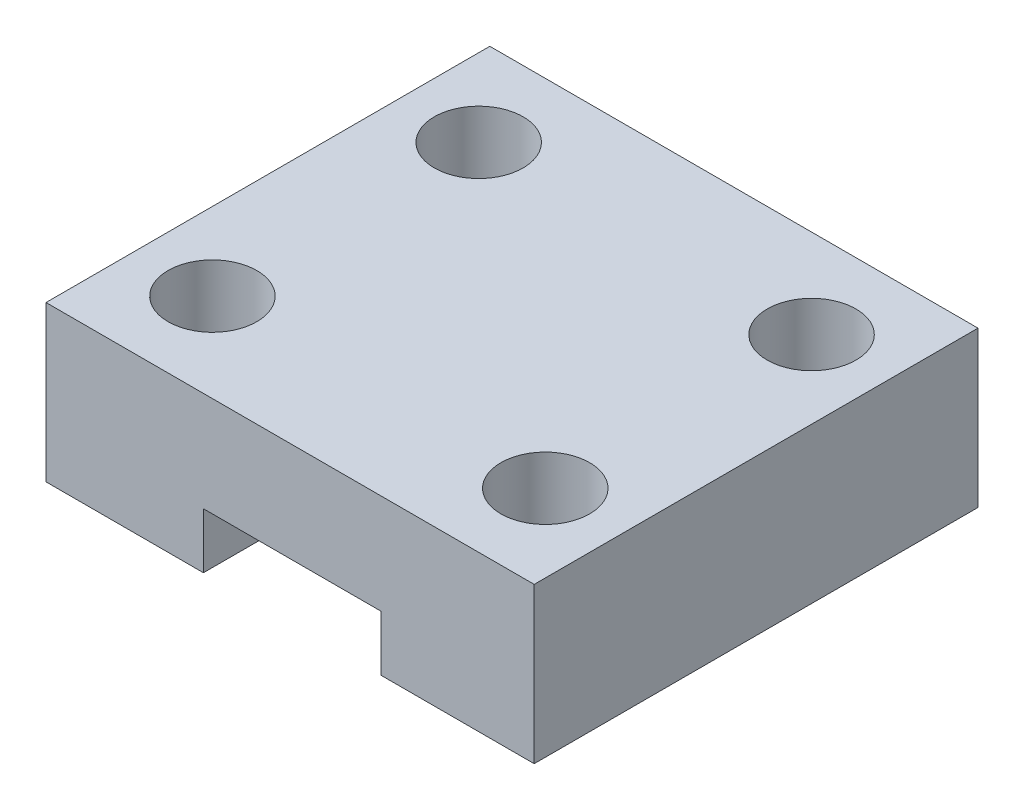
from build123d import *

# Parameters (mm, degrees)
SKETCH1_W                      = 44
SKETCH1_H                      = 40
SKETCH1_R                      = 4
BOSS_EXTRUDE1_DEPTH            = 14
CUT_EXTRUDE1_REACH             = 18.442
SKETCH2_W                      = 16
SKETCH2_H                      = 7.114924263
CUT_EXTRUDE1_DIRECTION_2_REACH = 25.558


with BuildPart() as part:
    # Sketch1 → Boss-Extrude1 (new body)
    with BuildSketch(Plane(origin=(0, 0, 0), x_dir=(1, 0, 0), z_dir=(0, 1, 0))):
        with Locations((-0.188936111, 3.557633072)):
            Rectangle(SKETCH1_W, SKETCH1_H)
        with Locations((14.811063889, -8.442366928)):
            Circle(SKETCH1_R, mode=Mode.SUBTRACT)
        with Locations((14.811063889, 15.557633072)):
            Circle(SKETCH1_R, mode=Mode.SUBTRACT)
        with Locations((-15.188936111, 15.557633072)):
            Circle(SKETCH1_R, mode=Mode.SUBTRACT)
        with Locations((-15.188936111, -8.442366928)):
            Circle(SKETCH1_R, mode=Mode.SUBTRACT)
    extrude(amount=BOSS_EXTRUDE1_DEPTH)

    # Cut-Extrude1: up to this face of the body (flat: up to its plane)
    cut_extrude1_end = Plane(part.part.faces().sort_by_distance((-0.188936111, 7, 16.442366928))[0])
    # Sketch2 → Cut-Extrude1 (cut, up to the picked face)
    with BuildSketch(Plane.XY, mode=Mode.PRIVATE) as cut_extrude1_sk1:
        with Locations((0, 1.442537868)):
            Rectangle(SKETCH2_W, SKETCH2_H)
    cut_extrude1_tool1 = split(extrude(cut_extrude1_sk1.sketch, amount=CUT_EXTRUDE1_REACH, mode=Mode.PRIVATE), bisect_by=cut_extrude1_end, keep=Keep.BOTH, mode=Mode.PRIVATE)
    add(cut_extrude1_tool1.solids().sort_by_distance((0, 1.442538, 0))[0], mode=Mode.SUBTRACT)

    # Cut-Extrude1 direction 2: up to this face of the body (flat: up to its plane)
    cut_extrude1_direction_2_end = Plane(part.part.faces().sort_by_distance((-0.188936111, 7, -23.557633072))[0])
    # Sketch2 → Cut-Extrude1 direction 2 (cut, up to the picked face)
    with BuildSketch(Plane.XY, mode=Mode.PRIVATE) as cut_extrude1_direction_2_sk1:
        with Locations((0, 1.442537868)):
            Rectangle(SKETCH2_W, SKETCH2_H)
    cut_extrude1_direction_2_tool1 = split(extrude(cut_extrude1_direction_2_sk1.sketch, amount=-CUT_EXTRUDE1_DIRECTION_2_REACH, mode=Mode.PRIVATE), bisect_by=cut_extrude1_direction_2_end, keep=Keep.BOTH, mode=Mode.PRIVATE)
    add(cut_extrude1_direction_2_tool1.solids().sort_by_distance((0, 1.442538, 0))[0], mode=Mode.SUBTRACT)


solid = part.part
